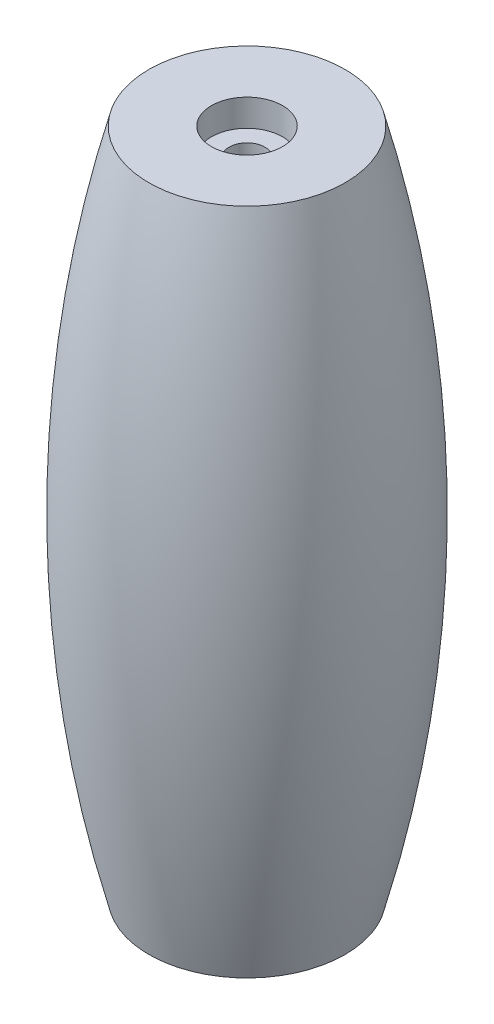
from build123d import *

# Parameters (mm, degrees)
SKETCH7_R          = 1.25
CUT_EXTRUDE6_DEPTH = 48.0000001
SKETCH8_R          = 2.5
CUT_EXTRUDE7_DEPTH = 1.9
SKETCH9_R          = 2.5
CUT_EXTRUDE8_DEPTH = 1.9
SCALE1_SCALE       = 0.95
SCALE2_SCALE       = 1.052631579
SCALE3_SCALE       = 0.94


with BuildPart() as part:
    # Sketch4 → Revolve2 (revolve)
    with BuildSketch(Plane.XY):
        with BuildLine():
            ThreePointArc((-12.188062192, 14.080894234), (-9.13116282, -9.419105766), (-12.188062192, -32.919105766))
            Line((-12.188062192, -32.919105766), (-19.089678679, -32.919105766))
            Line((-19.089678679, -32.919105766), (-19.089678679, 14.080894234))
            Line((-19.089678679, 14.080894234), (-12.188062192, 14.080894234))
        make_face()
    revolve(axis=Axis((-19.089678679, 14.080894234, 0), (0, -1, 0)))

    # Sketch7 → Cut-Extrude6 (cut, through all)
    with BuildSketch(Plane(origin=(0, 14.080894234, 0), x_dir=(1, 0, 0), z_dir=(0, 1, 0))):
        with Locations((-19.089678679, 0)):
            Circle(SKETCH7_R)
    extrude(amount=-CUT_EXTRUDE6_DEPTH, mode=Mode.SUBTRACT)

    # Sketch8 → Cut-Extrude7 (cut)
    with BuildSketch(Plane.XZ.offset(32.919105766)):
        with Locations((-19.089678679, 0)):
            Circle(SKETCH8_R)
    extrude(amount=-CUT_EXTRUDE7_DEPTH, mode=Mode.SUBTRACT)

    # Sketch9 → Cut-Extrude8 (cut)
    with BuildSketch(Plane(origin=(0, 14.080894234, 0), x_dir=(1, 0, 0), z_dir=(0, 1, 0))):
        with Locations((-19.089678679, 0)):
            Circle(SKETCH9_R)
    extrude(amount=-CUT_EXTRUDE8_DEPTH, mode=Mode.SUBTRACT)


with BuildPart() as part_1:
    # Scale1: scaled about (-19.089678679, -9.419105766, 0)
    add(part.part.scale(SCALE1_SCALE).moved(Location((-0.954483934, -0.470955288, 0))))


with BuildPart() as part_2:
    # Scale2: scaled about (-19.089678679, -9.419105766, 0)
    add(part_1.part.scale(SCALE2_SCALE).moved(Location((1.00471993, 0.495742409, 0))))


with BuildPart() as part_3:
    # Scale3: scaled about (-19.089678679, -9.419105766, 0)
    add(part_2.part.scale(SCALE3_SCALE).moved(Location((-1.145380721, -0.565146346, 0))))


solid = part_3.part
